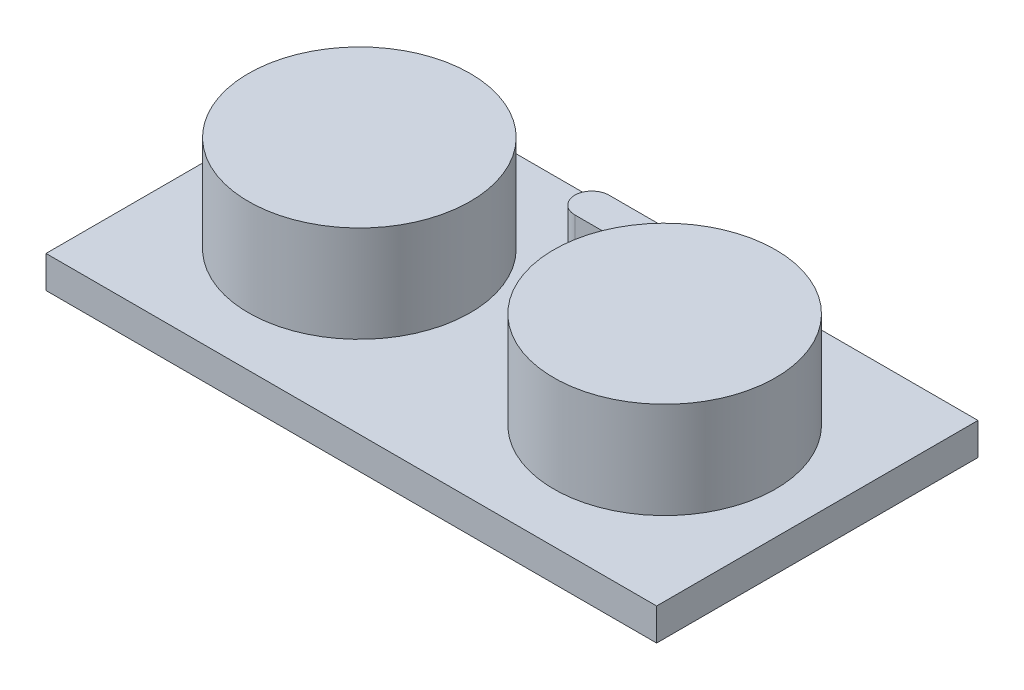
from build123d import *

# Parameters (mm, degrees)
SKETCH1_W           = 24.13
SKETCH1_H           = 25.4
SKETCH1_R           = 9.145310151
BOSS_EXTRUDE1_DEPTH = 2.54
SKETCH4_R           = 8.765161433
BOSS_EXTRUDE2_DEPTH = 7.62
BOSS_EXTRUDE3_START = -2.54
BOSS_EXTRUDE3_DEPTH = 5.08


with BuildPart() as part:
    # Sketch1 → Boss-Extrude1 (new body)
    with BuildSketch(Plane(origin=(0, 0, 0), x_dir=(1, 0, 0), z_dir=(0, 1, 0))):
        with Locations((-18.379392523, -7.539883178)):
            Rectangle(SKETCH1_W, SKETCH1_H)
        with Locations((-18.379392523, -7.539883178)):
            Circle(SKETCH1_R, mode=Mode.SUBTRACT)
        with Locations((5.750607477, -7.539883178)):
            Rectangle(SKETCH1_W, SKETCH1_H)
        with Locations((5.750607477, -7.539883178)):
            Circle(SKETCH1_R, mode=Mode.SUBTRACT)
        with Locations((5.750607477, -7.539883178)):
            Circle(SKETCH1_R)
        with Locations((-18.379392523, -7.539883178)):
            Circle(SKETCH1_R)
    extrude(amount=BOSS_EXTRUDE1_DEPTH)

    # Sketch4 → Boss-Extrude2 (add)
    with BuildSketch(Plane(origin=(0, 2.54, 0), x_dir=(1, 0, 0), z_dir=(0, 1, 0))):
        with Locations(Location((5.750607477, -7.539883178, 0), (0, 0, 90))):
            Circle(SKETCH4_R)
        with Locations(Location((-18.379392523, -7.539883178, 0), (0, 0, 90))):
            Circle(SKETCH4_R)
    extrude(amount=BOSS_EXTRUDE2_DEPTH)

    # Sketch5 → Boss-Extrude3 (add)
    with BuildSketch(Plane(origin=(0, 2.54, 0), x_dir=(1, 0, 0), z_dir=(0, 1, 0)).offset(BOSS_EXTRUDE3_START)):
        with BuildLine():
            Line((-9.642774863, 3.459380336), (-2.569962391, 3.459380336))
            ThreePointArc((-2.569962391, 3.459380336), (-1.217807066, 2.10722501), (-2.569962391, 0.755069685))
            Line((-2.569962391, 0.755069685), (-9.642774863, 0.755069685))
            ThreePointArc((-9.642774863, 0.755069685), (-10.994930189, 2.10722501), (-9.642774863, 3.459380336))
        make_face()
    extrude(amount=BOSS_EXTRUDE3_DEPTH)


solid = part.part
